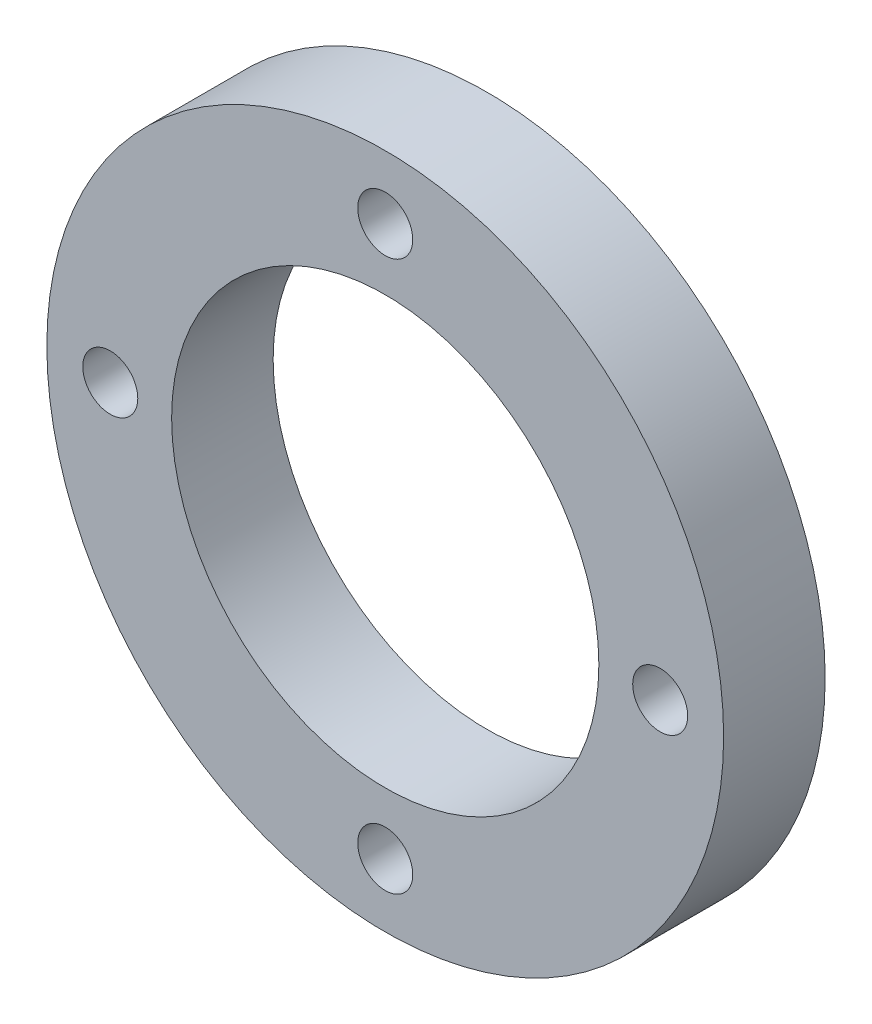
from build123d import *

# Parameters (mm, degrees)
SKETCH1_R           = 40
SKETCH1_R_2         = 25.25
SKETCH1_R_3         = 3.25
BOSS_EXTRUDE1_DEPTH = 6


with BuildPart() as part:
    # Sketch1 → Boss-Extrude1 (new body, symmetric)
    with BuildSketch(Plane.XY):
        Circle(SKETCH1_R)
        Circle(SKETCH1_R_2, mode=Mode.SUBTRACT)
        with Locations((-32.5, 0)):
            Circle(SKETCH1_R_3, mode=Mode.SUBTRACT)
        with Locations((0, 32.5)):
            Circle(SKETCH1_R_3, mode=Mode.SUBTRACT)
        with Locations((0, -32.5)):
            Circle(SKETCH1_R_3, mode=Mode.SUBTRACT)
        with Locations((32.5, 0)):
            Circle(SKETCH1_R_3, mode=Mode.SUBTRACT)
    extrude(amount=BOSS_EXTRUDE1_DEPTH, both=True)


solid = part.part
